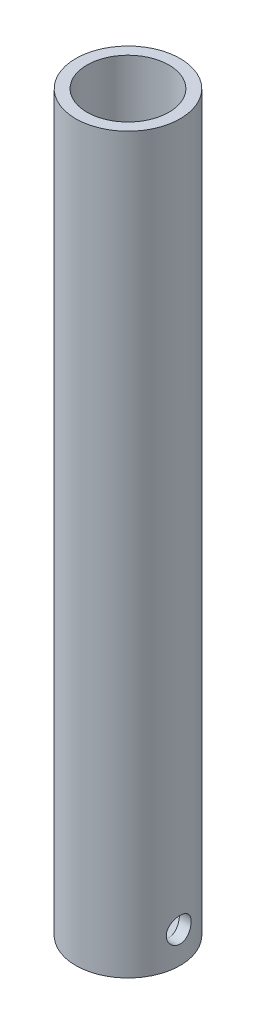
from build123d import *

# Parameters (mm, degrees)
SKETCH1_R           = 13.335
SKETCH1_R_2         = 10.4648
BOSS_EXTRUDE1_DEPTH = 187.325
SKETCH1_2_R         = 10.4648
BOSS_EXTRUDE2_DEPTH = 4.7625
SKETCH3_R           = 3.175
CUT_EXTRUDE1_DEPTH  = 14.351


with BuildPart() as part:
    # Sketch1 → Boss-Extrude1 (new body)
    with BuildSketch(Plane(origin=(0, 0, 0), x_dir=(1, 0, 0), z_dir=(0, 1, 0))):
        Circle(SKETCH1_R)
        Circle(SKETCH1_R_2, mode=Mode.SUBTRACT)
    extrude(amount=BOSS_EXTRUDE1_DEPTH)

    # Sketch1_2 → Boss-Extrude2 (add)
    with BuildSketch(Plane(origin=(0, 0, 0), x_dir=(1, 0, 0), z_dir=(0, 1, 0))):
        Circle(SKETCH1_2_R)
    extrude(amount=BOSS_EXTRUDE2_DEPTH)

    # Sketch3 → Cut-Extrude1 (cut)
    with BuildSketch(Plane(origin=(13.335, 0, 0), x_dir=(0, 0, -1), z_dir=(1, 0, 0))):
        with Locations((0, 7.9375)):
            Circle(SKETCH3_R)
    extrude(amount=-CUT_EXTRUDE1_DEPTH, mode=Mode.SUBTRACT)


solid = part.part
